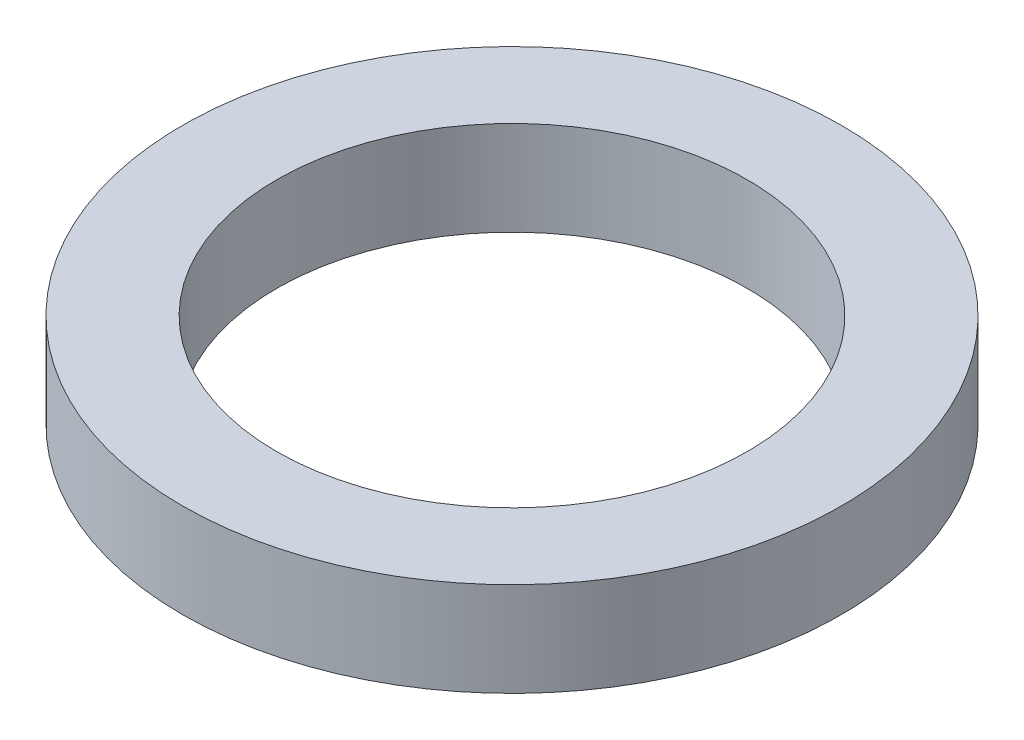
from build123d import *

# Parameters (mm, degrees)
SKETCH1_R           = 1.75
SKETCH1_R_2         = 1.25
BOSS_EXTRUDE1_DEPTH = 0.5


with BuildPart() as part:
    # Sketch1 → Boss-Extrude1 (new body)
    with BuildSketch(Plane(origin=(0, 0, 0), x_dir=(1, 0, 0), z_dir=(0, 1, 0))):
        Circle(SKETCH1_R)
        Circle(SKETCH1_R_2, mode=Mode.SUBTRACT)
    extrude(amount=BOSS_EXTRUDE1_DEPTH)


solid = part.part
